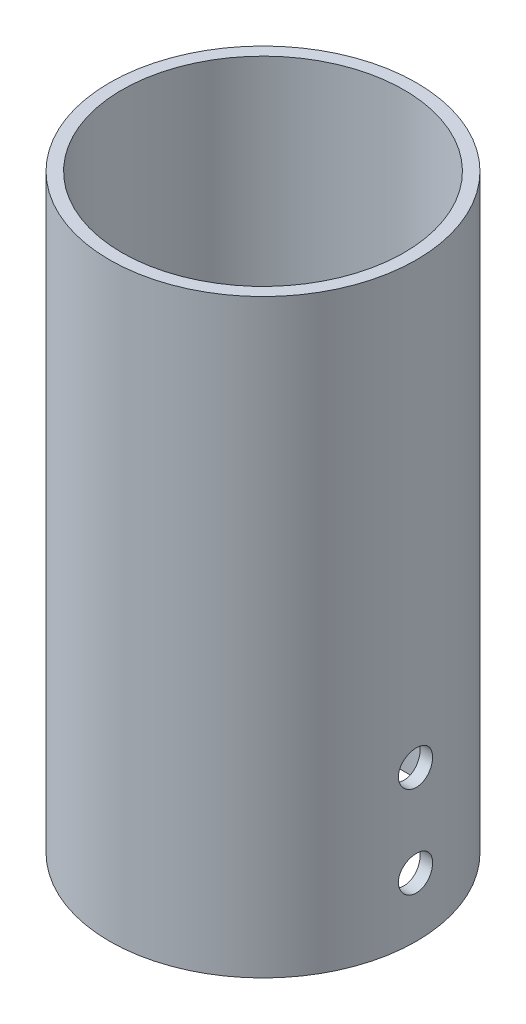
from build123d import *

# Parameters (mm, degrees)
SKETCH1_R               = 26
SKETCH1_R_2             = 23.9
BOSS_EXTRUDE1_DEPTH     = 100
SKETCH2_R               = 2.9
CUT_EXTRUDE1_DEPTH      = 27
CUT_EXTRUDE1_DEPTH_BACK = 27


with BuildPart() as part:
    # Sketch1 → Boss-Extrude1 (new body)
    with BuildSketch(Plane(origin=(0, 0, 0), x_dir=(1, 0, 0), z_dir=(0, 1, 0))):
        Circle(SKETCH1_R)
        Circle(SKETCH1_R_2, mode=Mode.SUBTRACT)
    extrude(amount=BOSS_EXTRUDE1_DEPTH)

    # Sketch2 → Cut-Extrude1 (cut, two sides)
    with BuildSketch(Plane(origin=(0, 0, 0), x_dir=(0, 0, -1), z_dir=(1, 0, 0))) as cut_extrude1_sk:
        with Locations((0, 10)):
            Circle(SKETCH2_R)
        with Locations((0, 25.5)):
            Circle(SKETCH2_R)
    extrude(amount=CUT_EXTRUDE1_DEPTH, mode=Mode.SUBTRACT)
    extrude(cut_extrude1_sk.sketch, amount=-CUT_EXTRUDE1_DEPTH_BACK, mode=Mode.SUBTRACT)


solid = part.part
